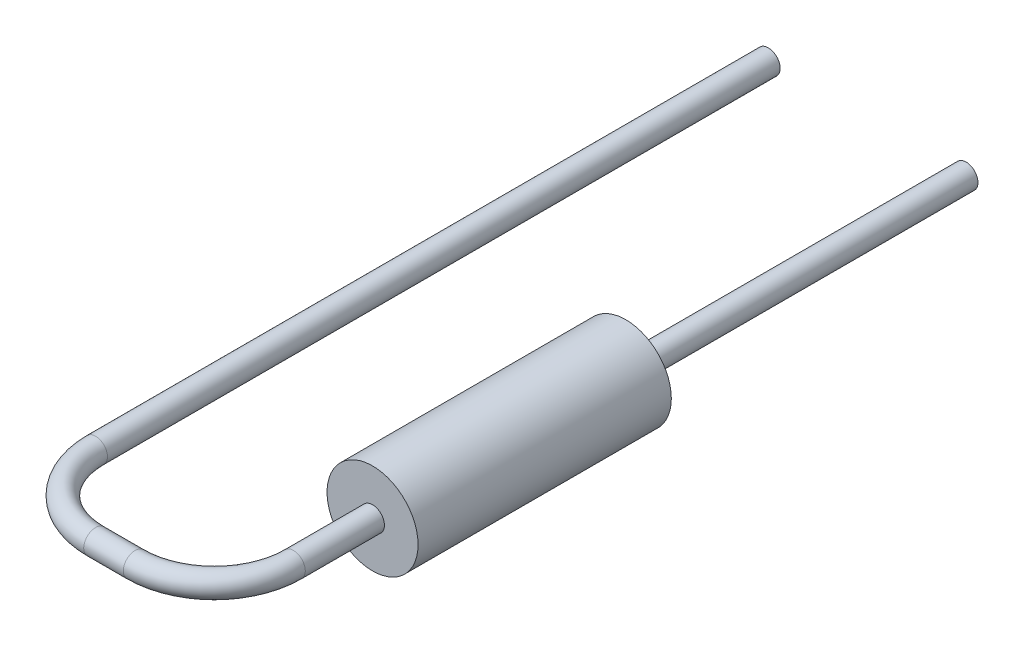
from build123d import *

# Parameters (mm, degrees)
SKETCH2_R           = 1.15
RESISTOR_BODY_DEPTH = 6.4
LEAD1_PROFILE_R     = 0.3
SKETCH6_R           = 0.3
LEAD2_DEPTH         = 8.6


with BuildPart() as part:
    # Sketch2 → Resistor Body (new body)
    with BuildSketch(Plane.XY):
        Circle(SKETCH2_R)
    extrude(amount=RESISTOR_BODY_DEPTH)

    # Lead1: sweep along a path in Lead1 Path
    with BuildLine(Plane(origin=(0, 0, 0), x_dir=(-1, 0, 0), z_dir=(0, -1, 0))) as lead1_path:
        Line((0, -6.4), (0, -8.4))
        ThreePointArc((0, -8.4), (0.585786438, -9.814213562), (2, -10.4))
        Line((2, -10.4), (3, -10.4))
        ThreePointArc((3, -10.4), (4.414213562, -9.814213562), (5, -8.4))
        Line((5, -8.4), (5, 8.6))
    # Lead1 Profile → Lead1 (sweep)
    with BuildSketch(Plane(origin=(0, 0, 6.4), x_dir=(-1, 0, 0), z_dir=(0, 0, 1))):
        Circle(LEAD1_PROFILE_R)
    sweep(path=lead1_path.line)

    # Sketch6 → Lead2 (add)
    with BuildSketch(Plane(origin=(0, 0, 0), x_dir=(1, 0, 0), z_dir=(0, 0, -1))):
        Circle(SKETCH6_R)
    extrude(amount=LEAD2_DEPTH)


solid = part.part
